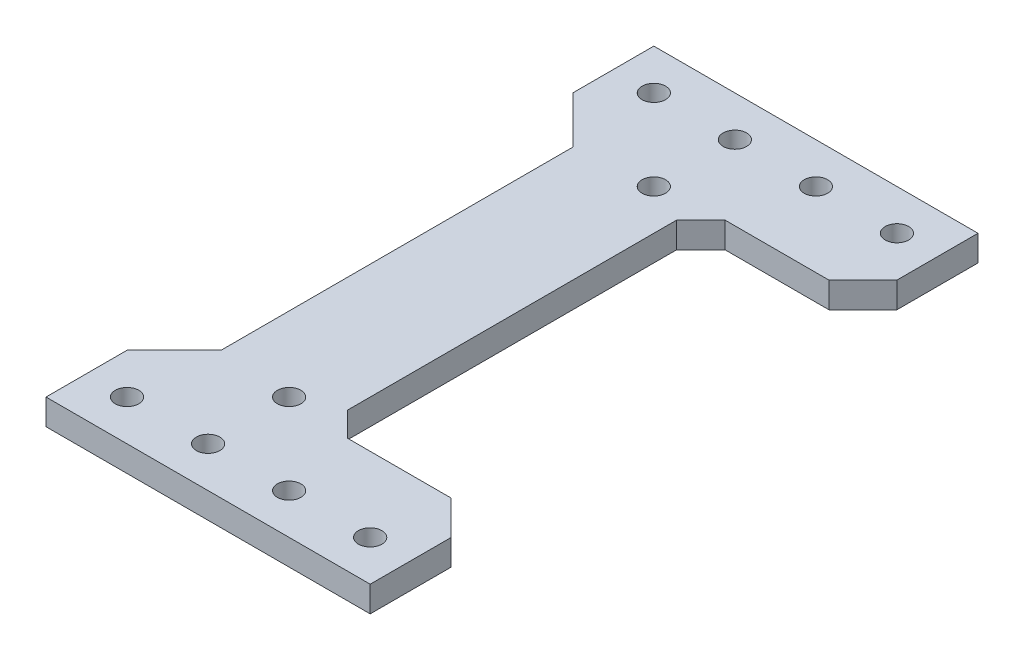
from build123d import *

# Parameters (mm, degrees)
SKETCH1_R           = 1.45
BOSS_EXTRUDE1_DEPTH = 3.175
CHAMFER1_SIZE       = 4.2
CHAMFER2_SIZE       = 3


with BuildPart() as part:
    # Sketch1 → Boss-Extrude1 (new body)
    with BuildSketch(Plane(origin=(0, 0, 0), x_dir=(1, 0, 0), z_dir=(0, 1, 0))):
        Polygon((5, 23.3), (25, 23.3), (25, 37.5), (-15, 37.5), (-15, 27.5), (-9.2, 21.7), (-9.2, 0), (5, 0), align=None)
        with Locations((0, 22.5)):
            Circle(SKETCH1_R, mode=Mode.SUBTRACT)
        with Locations((-10, 32.5)):
            Circle(SKETCH1_R, mode=Mode.SUBTRACT)
        with Locations((20, 32.5)):
            Circle(SKETCH1_R, mode=Mode.SUBTRACT)
        with Locations((0, 32.5)):
            Circle(SKETCH1_R, mode=Mode.SUBTRACT)
        with Locations((10, 32.5)):
            Circle(SKETCH1_R, mode=Mode.SUBTRACT)
    boss_extrude1 = extrude(amount=BOSS_EXTRUDE1_DEPTH)

    # Mirror1: Boss-Extrude1 across plane
    add(boss_extrude1.mirror(Plane(origin=(5, 3.175, 0), x_dir=(1, 0, 0), z_dir=(0, 0, -1))))

    # Chamfer1
    chamfer1_edges = [part.edges().sort_by_distance(p)[0] for p in [
        (25, 1.5875, -23.3),
        (25, 1.5875, 23.3),
    ]]
    chamfer(chamfer1_edges, length=CHAMFER1_SIZE)

    # Chamfer2
    chamfer2_edges = [part.edges().sort_by_distance(p)[0] for p in [
        (5, 1.5875, -23.3),
        (5, 1.5875, 23.3),
    ]]
    chamfer(chamfer2_edges, length=CHAMFER2_SIZE)


solid = part.part
